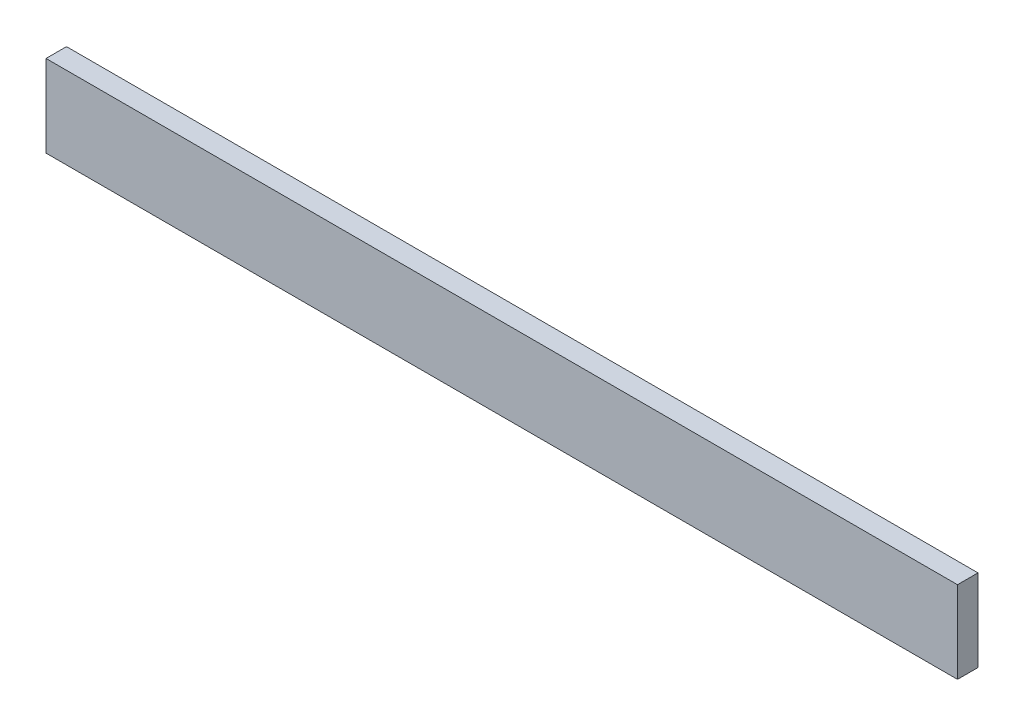
from build123d import *

# Parameters (mm, degrees)
SKETCH1_W           = 141.170394877
SKETCH1_H           = 12.7
BOSS_EXTRUDE1_DEPTH = 3.175


with BuildPart() as part:
    # Sketch1 → Boss-Extrude1 (new body)
    with BuildSketch(Plane.XY):
        with Locations((45.055131735, -71.128595286)):
            Rectangle(SKETCH1_W, SKETCH1_H)
    extrude(amount=BOSS_EXTRUDE1_DEPTH)


solid = part.part
